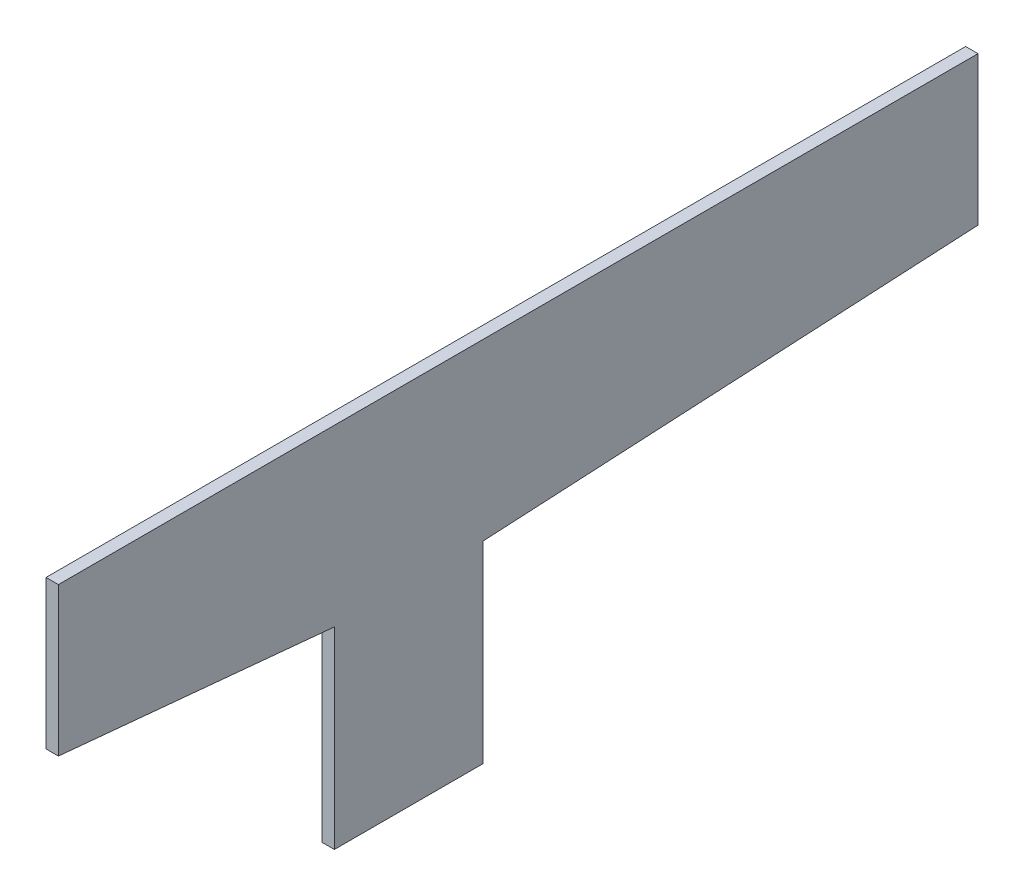
from build123d import *

# Parameters (mm, degrees)
BOSS_EXTRUDE1_DEPTH = 1.5875


with BuildPart() as part:
    # Sketch2 → Boss-Extrude1 (new body, symmetric)
    with BuildSketch(Plane(origin=(0, 0, 0), x_dir=(0, 0, -1), z_dir=(1, 0, 0))):
        Polygon((-19.05, 11.350000004), (-19.05, -38.1), (19.05, -38.1), (19.05, 11.350000004), (146.05, 18.050000001), (146.05, 56.150000001), (-89.85, 56.150000001), (-89.85, 18.050000001), align=None)
    extrude(amount=BOSS_EXTRUDE1_DEPTH, both=True)


solid = part.part
